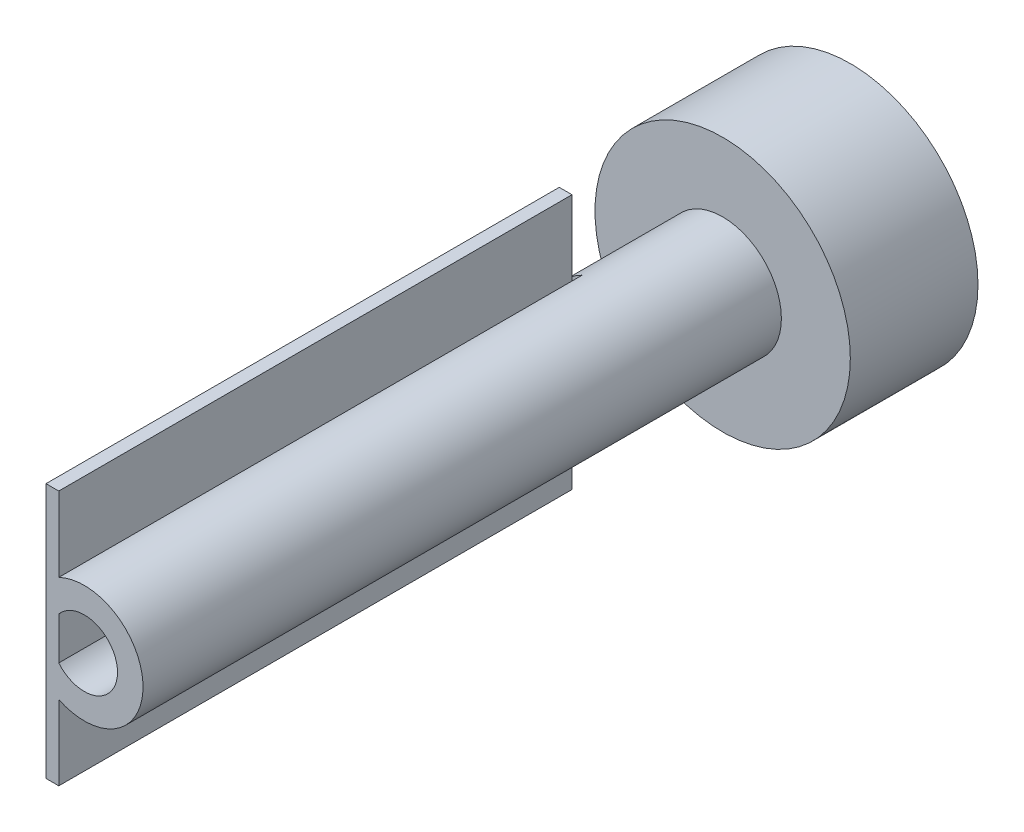
from build123d import *

# Parameters (mm, degrees)
SKETCH_1_R          = 10
SKETCH_1_R_2        = 2.6
EXTRUDE_1_DEPTH     = 10
SKETCH_2_R          = 4.6
SKETCH_2_R_2        = 2.6
EXTRUDE_2_DEPTH     = 50
CUT_EXTRUDE_1_DEPTH = 41
SKETCH_5_W          = 1
SKETCH_5_H          = 20
EXTRUDE_3_DEPTH     = 40.2


with BuildPart() as part:
    # 草图1 → 凸台-拉伸1 (new body)
    with BuildSketch(Plane.XY):
        Circle(SKETCH_1_R)
        Circle(SKETCH_1_R_2, mode=Mode.SUBTRACT)
    extrude(amount=EXTRUDE_1_DEPTH)

    # 草图2 → 凸台-拉伸2 (add)
    with BuildSketch(Plane.XY.offset(10)):
        Circle(SKETCH_2_R)
        Circle(SKETCH_2_R_2, mode=Mode.SUBTRACT)
    extrude(amount=EXTRUDE_2_DEPTH)

    # 草图3 → 切除-拉伸1 (cut)
    with BuildSketch(Plane.XY.offset(60)):
        with BuildLine():
            Line((-2, 4.142463035), (-2, -4.142463035))
            ThreePointArc((-2, -4.142463035), (-4.6, 0), (-2, 4.142463035))
        make_face()
    extrude(amount=-CUT_EXTRUDE_1_DEPTH, mode=Mode.SUBTRACT)

    # 草图5 → 凸台-拉伸3 (add)
    with BuildSketch(Plane.XY.offset(60)):
        with Locations((-2.5, 0)):
            Rectangle(SKETCH_5_W, SKETCH_5_H)
    extrude(amount=-EXTRUDE_3_DEPTH)


solid = part.part
